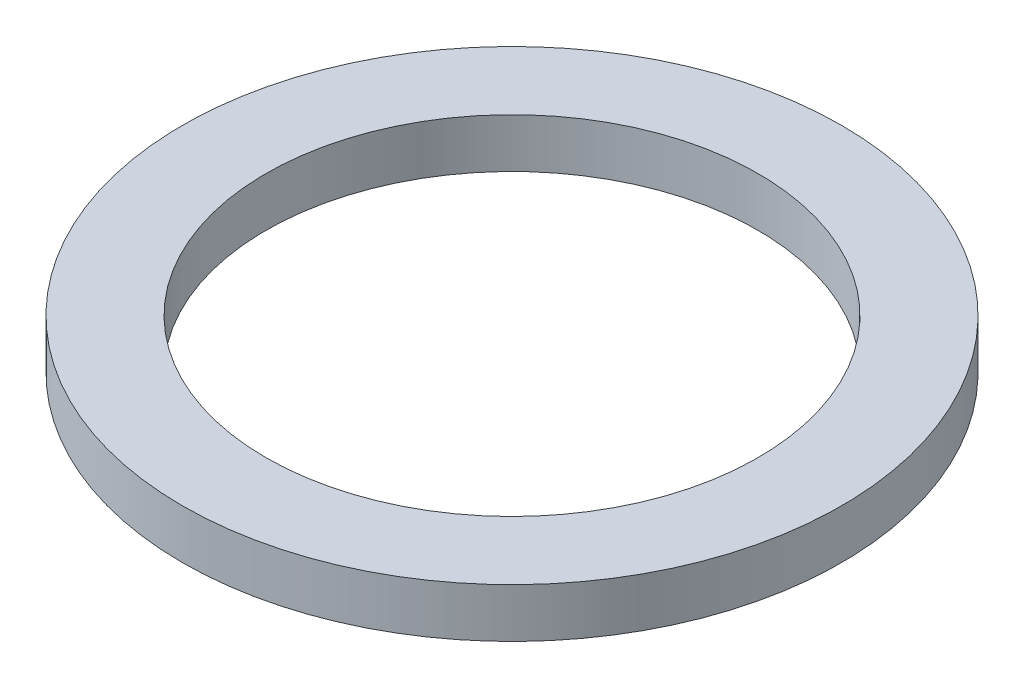
from build123d import *

# Parameters (mm, degrees)
SKETCH1_R           = 4.7625
BOSS_EXTRUDE1_DEPTH = 0.7112
SKETCH5_R           = 3.556
CUT_EXTRUDE1_DEPTH  = 1.7112


with BuildPart() as part:
    # Sketch1 → Boss-Extrude1 (new body)
    with BuildSketch(Plane(origin=(0, 0, 0), x_dir=(1, 0, 0), z_dir=(0, 1, 0))):
        Circle(SKETCH1_R)
    extrude(amount=BOSS_EXTRUDE1_DEPTH)

    # Sketch5 → Cut-Extrude1 (cut, through all)
    with BuildSketch(Plane(origin=(0, 0.7112, 0), x_dir=(-1, 0, 0), z_dir=(0, 1, 0))):
        Circle(SKETCH5_R)
    extrude(amount=-CUT_EXTRUDE1_DEPTH, mode=Mode.SUBTRACT)


solid = part.part
